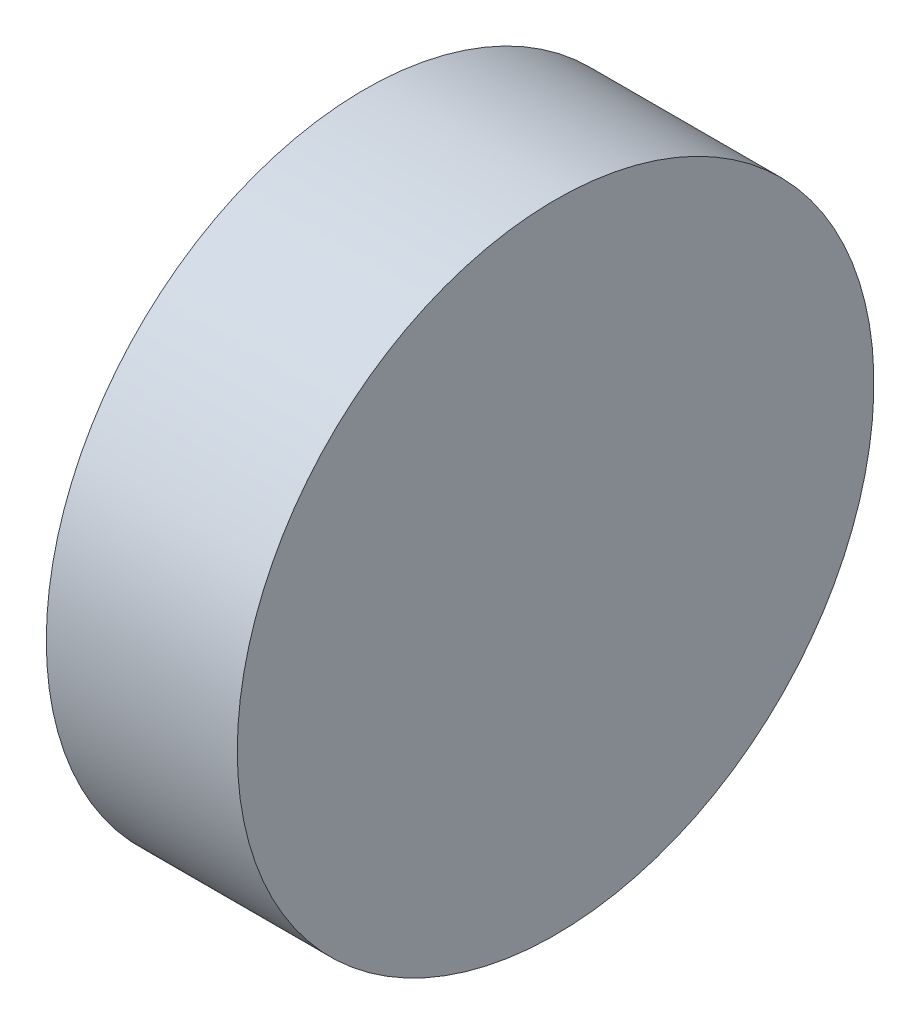
from build123d import *

# Parameters (mm, degrees)
SKETCH_1_W = 6
SKETCH_1_H = 10


with BuildPart() as part:
    # 草图1 → 旋转1 (revolve)
    with BuildSketch(Plane.XY, mode=Mode.PRIVATE) as revolve_1_sk:
        with Locations((133.100867636, 43.646589675)):
            Rectangle(SKETCH_1_W, SKETCH_1_H)
    revolve(revolve_1_sk.sketch.rotate(Axis((127.000400996, 38.646589675, 0), (1, 0, 0)), 90), axis=Axis((127.000400996, 38.646589675, 0), (1, 0, 0)))  # turned: the seam where the file's is


solid = part.part
